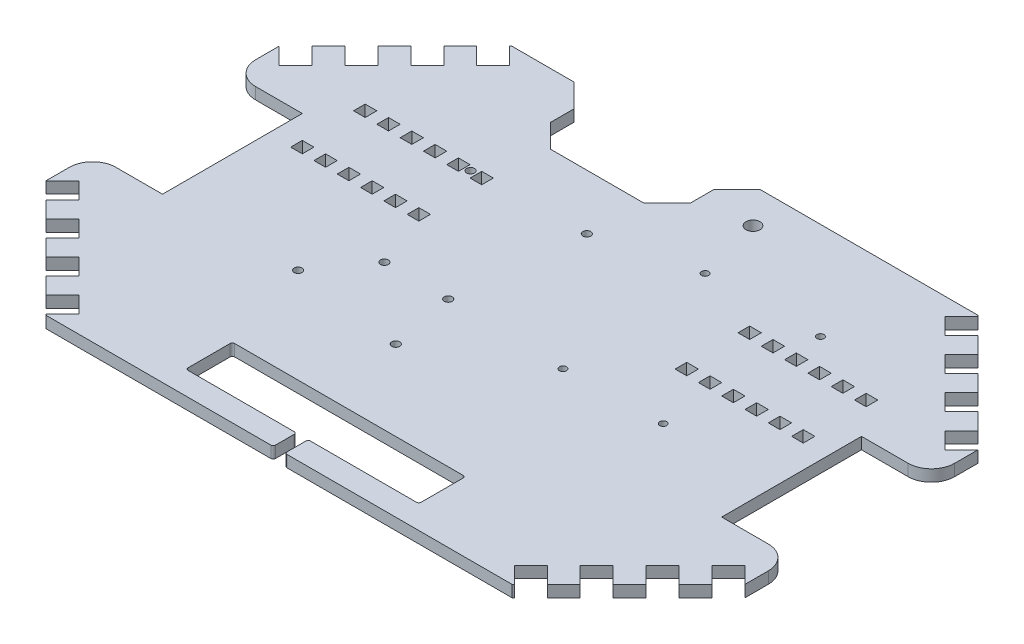
from build123d import *

# Parameters (mm, degrees)
ESQUISSE1_W                = 300
ESQUISSE1_H                = 200
BOSS_EXTRU_1_DEPTH         = 5
ENL_V_MAT_EXTRU_1_DEPTH    = 10
ENL_V_MAT_EXTRU_5_DEPTH    = 10
R_P_TITION_LIN_AIRE2_COUNT = 4
R_P_TITION_LIN_AIRE2_PITCH = 20
SYM_TRIE1_COPY_1_DEPTH     = 10
SYM_TRIE1_COPY_2_DEPTH     = 10
SYM_TRIE1_COPY_3_DEPTH     = 10
ESQUISSE11_W               = 30
ESQUISSE11_H               = 15
ENL_V_MAT_EXTRU_10_DEPTH   = 10
SYM_TRIE2_COPY_1_DEPTH     = 10
SYM_TRIE2_COPY_2_DEPTH     = 10
SYM_TRIE2_COPY_3_DEPTH     = 10
SYM_TRIE2_COPY_4_DEPTH     = 10
SYM_TRIE2_COPY_5_DEPTH     = 10
SYM_TRIE2_COPY_6_DEPTH     = 10
SYM_TRIE2_COPY_7_DEPTH     = 10
ESQUISSE17_W               = 60
ESQUISSE17_H               = 30
ENL_V_MAT_EXTRU_16_DEPTH   = 10
CHANFREIN1_SIZE            = 10
ESQUISSE18_W               = 30
ESQUISSE18_H               = 60
ENL_V_MAT_EXTRU_17_DEPTH   = 10
ESQUISSE20_R               = 3
ENL_V_MAT_EXTRU_19_DEPTH   = 10
ESQUISSE21_W               = 5
ESQUISSE21_H               = 5
ENL_V_MAT_EXTRU_20_DEPTH   = 10
ESQUISSE22_W               = 100
ESQUISSE22_H               = 20
ESQUISSE22_W_2             = 5
ESQUISSE22_H_2             = 10
ENL_V_MAT_EXTRU_21_DEPTH   = 10
CONG_1_R                   = 1
ESQUISSE23_R               = 1.5
ENL_V_MAT_EXTRU_23_DEPTH   = 10
ESQUISSE24_R               = 1.7
ENL_V_MAT_EXTRU_24_DEPTH   = 10
CONG_2_R                   = 10


with BuildPart() as part:
    # Esquisse1 → Boss.-Extru.1 (new body)
    with BuildSketch(Plane(origin=(0, 0, 0), x_dir=(1, 0, 0), z_dir=(0, 1, 0))):
        Rectangle(ESQUISSE1_W, ESQUISSE1_H)
    extrude(amount=BOSS_EXTRU_1_DEPTH)

    # Esquisse2 → Enlèv. mat.-Extru.1 (cut)
    with BuildSketch(Plane(origin=(0, 5, 0), x_dir=(1, 0, 0), z_dir=(0, 1, 0))):
        Polygon((-100, 100), (-150, 50), (-150, 100), align=None)
        Polygon((150, 100), (150, 50), (100, 100), align=None)
        Polygon((150, -100), (150, -50), (100, -100), align=None)
        Polygon((-100, -100), (-150, -100), (-150, -50), align=None)
    extrude(amount=-ENL_V_MAT_EXTRU_1_DEPTH, mode=Mode.SUBTRACT)

    # Esquisse6 → Enlèv. mat.-Extru.5 (cut)
    with BuildSketch(Plane(origin=(0, 5, 0), x_dir=(1, 0, 0), z_dir=(0, 1, 0))):
        Polygon((-142.928932188, 57.071067812), (-150, 50), (-142.928932188, 42.928932188), (-135.857864376, 50), align=None)
    enl_v_mat_extru_5 = extrude(amount=-ENL_V_MAT_EXTRU_5_DEPTH, mode=Mode.SUBTRACT)

    # Répétition linéaire2: Enlèv. mat.-Extru.5 ×4
    with Locations(*[Vector(0.707106781, 0, -0.707106781) * (i * R_P_TITION_LIN_AIRE2_PITCH) for i in range(1, R_P_TITION_LIN_AIRE2_COUNT)]):
        add(enl_v_mat_extru_5, mode=Mode.SUBTRACT)

    # Symétrie1: Enlèv. mat.-Extru.5 across plane
    add(enl_v_mat_extru_5.mirror(Plane.XY), mode=Mode.SUBTRACT)

    # Symétrie1 copy 1 sketch → Symétrie1 copy 1 (cut)
    with BuildSketch(Plane(origin=(14.142135624, 5, 14.142135624), x_dir=(1, 0, 0), z_dir=(0, 1, 0))):
        Polygon((-142.928932188, -57.071067812), (-150, -50), (-142.928932188, -42.928932188), (-135.857864376, -50), align=None)
    extrude(amount=-SYM_TRIE1_COPY_1_DEPTH, mode=Mode.SUBTRACT)

    # Symétrie1 copy 2 sketch → Symétrie1 copy 2 (cut)
    with BuildSketch(Plane(origin=(28.284271247, 5, 28.284271247), x_dir=(1, 0, 0), z_dir=(0, 1, 0))):
        Polygon((-142.928932188, -57.071067812), (-150, -50), (-142.928932188, -42.928932188), (-135.857864376, -50), align=None)
    extrude(amount=-SYM_TRIE1_COPY_2_DEPTH, mode=Mode.SUBTRACT)

    # Symétrie1 copy 3 sketch → Symétrie1 copy 3 (cut)
    with BuildSketch(Plane(origin=(42.426406871, 5, 42.426406871), x_dir=(1, 0, 0), z_dir=(0, 1, 0))):
        Polygon((-142.928932188, -57.071067812), (-150, -50), (-142.928932188, -42.928932188), (-135.857864376, -50), align=None)
    extrude(amount=-SYM_TRIE1_COPY_3_DEPTH, mode=Mode.SUBTRACT)

    # Esquisse11 → Enlèv. mat.-Extru.10 (cut)
    with BuildSketch(Plane(origin=(0, 5, 0), x_dir=(1, 0, 0), z_dir=(0, 1, 0))):
        with Locations((135, 0)):
            Rectangle(ESQUISSE11_W, ESQUISSE11_H)
    enl_v_mat_extru_10 = extrude(amount=-ENL_V_MAT_EXTRU_10_DEPTH, mode=Mode.SUBTRACT)

    # Symétrie2: Enlèv. mat.-Extru.10, Enlèv. mat.-Extru.5 across plane
    add(enl_v_mat_extru_10.mirror(Plane(origin=(0, 0, 0), x_dir=(0, 0, 1), z_dir=(1, 0, 0))), mode=Mode.SUBTRACT)
    add(enl_v_mat_extru_5.mirror(Plane(origin=(0, 0, 0), x_dir=(0, 0, 1), z_dir=(1, 0, 0))), mode=Mode.SUBTRACT)

    # Symétrie2 copy 1 sketch → Symétrie2 copy 1 (cut)
    with BuildSketch(Plane(origin=(0, 5, 0), x_dir=(-1, 0, 0), z_dir=(0, 1, 0))):
        Polygon((-142.928932188, 57.071067812), (-150, 50), (-142.928932188, 42.928932188), (-135.857864376, 50), align=None)
    extrude(amount=-SYM_TRIE2_COPY_1_DEPTH, mode=Mode.SUBTRACT)

    # Symétrie2 copy 2 sketch → Symétrie2 copy 2 (cut)
    with BuildSketch(Plane(origin=(-14.142135624, 5, 14.142135624), x_dir=(-1, 0, 0), z_dir=(0, 1, 0))):
        Polygon((-142.928932188, 57.071067812), (-150, 50), (-142.928932188, 42.928932188), (-135.857864376, 50), align=None)
    extrude(amount=-SYM_TRIE2_COPY_2_DEPTH, mode=Mode.SUBTRACT)

    # Symétrie2 copy 3 sketch → Symétrie2 copy 3 (cut)
    with BuildSketch(Plane(origin=(-28.284271247, 5, 28.284271247), x_dir=(-1, 0, 0), z_dir=(0, 1, 0))):
        Polygon((-142.928932188, 57.071067812), (-150, 50), (-142.928932188, 42.928932188), (-135.857864376, 50), align=None)
    extrude(amount=-SYM_TRIE2_COPY_3_DEPTH, mode=Mode.SUBTRACT)

    # Symétrie2 copy 4 sketch → Symétrie2 copy 4 (cut)
    with BuildSketch(Plane(origin=(-42.426406871, 5, 42.426406871), x_dir=(-1, 0, 0), z_dir=(0, 1, 0))):
        Polygon((-142.928932188, 57.071067812), (-150, 50), (-142.928932188, 42.928932188), (-135.857864376, 50), align=None)
    extrude(amount=-SYM_TRIE2_COPY_4_DEPTH, mode=Mode.SUBTRACT)

    # Symétrie2 copy 5 sketch → Symétrie2 copy 5 (cut)
    with BuildSketch(Plane(origin=(-14.142135624, 5, -14.142135624), x_dir=(-1, 0, 0), z_dir=(0, 1, 0))):
        Polygon((-142.928932188, -57.071067812), (-150, -50), (-142.928932188, -42.928932188), (-135.857864376, -50), align=None)
    extrude(amount=-SYM_TRIE2_COPY_5_DEPTH, mode=Mode.SUBTRACT)

    # Symétrie2 copy 6 sketch → Symétrie2 copy 6 (cut)
    with BuildSketch(Plane(origin=(-28.284271247, 5, -28.284271247), x_dir=(-1, 0, 0), z_dir=(0, 1, 0))):
        Polygon((-142.928932188, -57.071067812), (-150, -50), (-142.928932188, -42.928932188), (-135.857864376, -50), align=None)
    extrude(amount=-SYM_TRIE2_COPY_6_DEPTH, mode=Mode.SUBTRACT)

    # Symétrie2 copy 7 sketch → Symétrie2 copy 7 (cut)
    with BuildSketch(Plane(origin=(-42.426406871, 5, -42.426406871), x_dir=(-1, 0, 0), z_dir=(0, 1, 0))):
        Polygon((-142.928932188, -57.071067812), (-150, -50), (-142.928932188, -42.928932188), (-135.857864376, -50), align=None)
    extrude(amount=-SYM_TRIE2_COPY_7_DEPTH, mode=Mode.SUBTRACT)

    # Esquisse17 → Enlèv. mat.-Extru.16 (cut)
    with BuildSketch(Plane(origin=(0, 5, 0), x_dir=(1, 0, 0), z_dir=(0, 1, 0))):
        with Locations((-33.431457505, 85)):
            Rectangle(ESQUISSE17_W, ESQUISSE17_H)
    extrude(amount=-ENL_V_MAT_EXTRU_16_DEPTH, mode=Mode.SUBTRACT)

    # Chanfrein1
    chanfrein1_edges = [part.edges().sort_by_distance(p)[0] for p in [
        (-63.431457505, 2.5, -100),
        (-3.431457505, 2.5, -100),
        (-3.431457505, 2.5, -70),
        (-63.431457505, 2.5, -70),
    ]]
    chamfer(chanfrein1_edges, length=CHANFREIN1_SIZE)

    # Esquisse18 → Enlèv. mat.-Extru.17 (cut)
    with BuildSketch(Plane(origin=(0, 5, 0), x_dir=(1, 0, 0), z_dir=(0, 1, 0))):
        with Locations((-135, 0)):
            Rectangle(ESQUISSE18_W, ESQUISSE18_H)
        with Locations((135, 0)):
            Rectangle(ESQUISSE18_W, ESQUISSE18_H)
    extrude(amount=-ENL_V_MAT_EXTRU_17_DEPTH, mode=Mode.SUBTRACT)

    # Esquisse20 → Enlèv. mat.-Extru.19 (cut)
    with BuildSketch(Plane.XZ):
        with Locations((18.431457505, -85)):
            Circle(ESQUISSE20_R)
    extrude(amount=-ENL_V_MAT_EXTRU_19_DEPTH, mode=Mode.SUBTRACT)

    # Esquisse21 → Enlèv. mat.-Extru.20 (cut)
    with BuildSketch(Plane.XZ):
        with Locations((107.5, -44.5)):
            Rectangle(ESQUISSE21_W, ESQUISSE21_H)
        with Locations((97.5, -44.5)):
            Rectangle(ESQUISSE21_W, ESQUISSE21_H)
        with Locations((87.5, -44.5)):
            Rectangle(ESQUISSE21_W, ESQUISSE21_H)
        with Locations((77.5, -44.5)):
            Rectangle(ESQUISSE21_W, ESQUISSE21_H)
        with Locations((67.5, -44.5)):
            Rectangle(ESQUISSE21_W, ESQUISSE21_H)
        with Locations((57.5, -44.5)):
            Rectangle(ESQUISSE21_W, ESQUISSE21_H)
        with Locations((97.5, -17.5)):
            Rectangle(ESQUISSE21_W, ESQUISSE21_H)
        with Locations((107.5, -17.5)):
            Rectangle(ESQUISSE21_W, ESQUISSE21_H)
        with Locations((87.5, -17.5)):
            Rectangle(ESQUISSE21_W, ESQUISSE21_H)
        with Locations((77.5, -17.5)):
            Rectangle(ESQUISSE21_W, ESQUISSE21_H)
        with Locations((67.5, -17.5)):
            Rectangle(ESQUISSE21_W, ESQUISSE21_H)
        with Locations((57.5, -17.5)):
            Rectangle(ESQUISSE21_W, ESQUISSE21_H)
        with Locations((-57.5, -17.5)):
            Rectangle(ESQUISSE21_W, ESQUISSE21_H)
        with Locations((-67.5, -17.5)):
            Rectangle(ESQUISSE21_W, ESQUISSE21_H)
        with Locations((-77.5, -17.5)):
            Rectangle(ESQUISSE21_W, ESQUISSE21_H)
        with Locations((-87.5, -17.5)):
            Rectangle(ESQUISSE21_W, ESQUISSE21_H)
        with Locations((-97.5, -17.5)):
            Rectangle(ESQUISSE21_W, ESQUISSE21_H)
        with Locations((-107.5, -17.5)):
            Rectangle(ESQUISSE21_W, ESQUISSE21_H)
        with Locations((-57.5, -44.5)):
            Rectangle(ESQUISSE21_W, ESQUISSE21_H)
        with Locations((-67.5, -44.5)):
            Rectangle(ESQUISSE21_W, ESQUISSE21_H)
        with Locations((-77.5, -44.5)):
            Rectangle(ESQUISSE21_W, ESQUISSE21_H)
        with Locations((-87.5, -44.5)):
            Rectangle(ESQUISSE21_W, ESQUISSE21_H)
        with Locations((-97.5, -44.5)):
            Rectangle(ESQUISSE21_W, ESQUISSE21_H)
        with Locations((-107.5, -44.5)):
            Rectangle(ESQUISSE21_W, ESQUISSE21_H)
    extrude(amount=-ENL_V_MAT_EXTRU_20_DEPTH, mode=Mode.SUBTRACT)

    # Esquisse22 → Enlèv. mat.-Extru.21 (cut)
    with BuildSketch(Plane.XZ):
        with Locations((0, 80)):
            Rectangle(ESQUISSE22_W, ESQUISSE22_H)
        with Locations((0, 95)):
            Rectangle(ESQUISSE22_W_2, ESQUISSE22_H_2)
    extrude(amount=-ENL_V_MAT_EXTRU_21_DEPTH, mode=Mode.SUBTRACT)

    # Congé1
    cong_1_edges = [part.edges().sort_by_distance(p)[0] for p in [
        (2.5, 2.5, 100),
        (-2.5, 2.5, 100),
        (2.5, 2.5, 90),
        (50, 2.5, 90),
        (50, 2.5, 70),
        (-50, 2.5, 70),
        (-50, 2.5, 90),
        (-2.5, 2.5, 90),
    ]]
    fillet(cong_1_edges, radius=CONG_1_R)

    # Esquisse23 → Enlèv. mat.-Extru.23 (cut)
    with BuildSketch(Plane.XZ):
        with Locations((30.815144005, 8.946737652)):
            Circle(ESQUISSE23_R)
        with Locations((72.709938735, 7.817899956)):
            Circle(ESQUISSE23_R)
        with Locations((25.862521369, -56.983784521)):
            Circle(ESQUISSE23_R)
        with Locations((74.10501227, -58.283658232)):
            Circle(ESQUISSE23_R)
    extrude(amount=-ENL_V_MAT_EXTRU_23_DEPTH, mode=Mode.SUBTRACT)

    # Esquisse24 → Enlèv. mat.-Extru.24 (cut)
    with BuildSketch(Plane(origin=(0, 0, 0), x_dir=(-1, 0, 0), z_dir=(0, -1, 0))):
        with Locations((62.61767709, -29.162375727)):
            Circle(ESQUISSE24_R)
        with Locations((62.61767709, 44.837624273)):
            Circle(ESQUISSE24_R)
        with Locations((14.21767709, 46.337624273)):
            Circle(ESQUISSE24_R)
        with Locations((14.21767709, -35.662375727)):
            Circle(ESQUISSE24_R)
        with Locations((47.11767709, -7.662375727)):
            Circle(ESQUISSE24_R)
        with Locations((19.71767709, -7.662375727)):
            Circle(ESQUISSE24_R)
    extrude(amount=-ENL_V_MAT_EXTRU_24_DEPTH, mode=Mode.SUBTRACT)

    # Congé2
    cong_2_edges = [part.edges().sort_by_distance(p)[0] for p in [
        (-150, 2.5, -30),
        (-150, 2.5, 30),
        (150, 2.5, 30),
        (150, 2.5, -30),
    ]]
    fillet(cong_2_edges, radius=CONG_2_R)


solid = part.part
